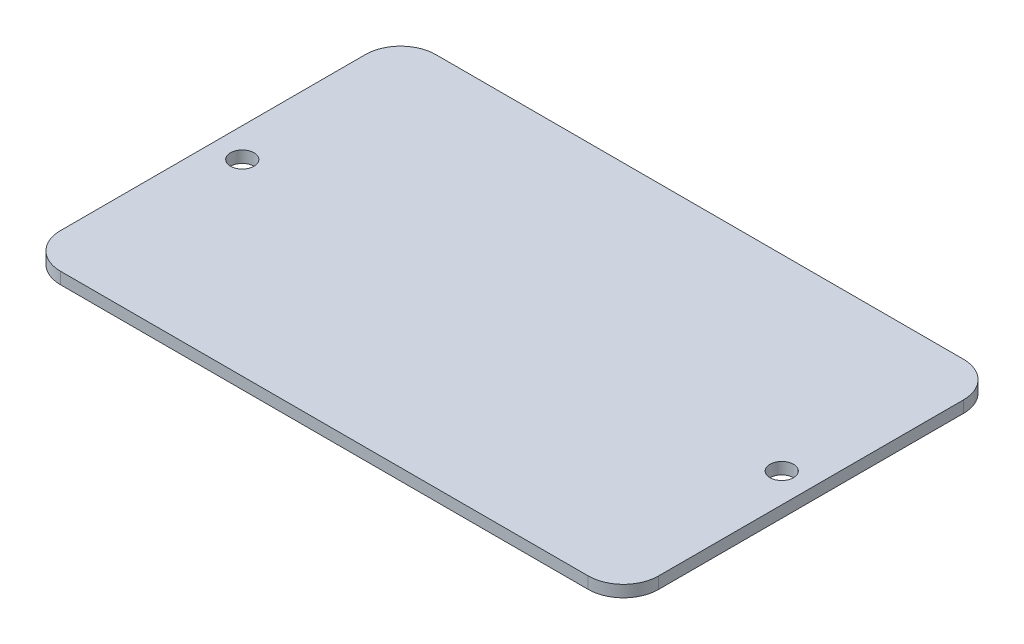
from build123d import *

# Parameters (mm, degrees)
SKETCH1_W           = 80.9625
SKETCH1_H           = 50.8
SKETCH1_R           = 1.5875
BOSS_EXTRUDE1_DEPTH = 1.5875
FILLET1_R           = 4.7625


with BuildPart() as part:
    # Sketch1 → Boss-Extrude1 (new body)
    with BuildSketch(Plane(origin=(0, 0, 0), x_dir=(1, 0, 0), z_dir=(0, 1, 0))):
        with Locations((40.48125, 25.4)):
            Rectangle(SKETCH1_W, SKETCH1_H)
        with Locations((3.96875, 25.4)):
            Circle(SKETCH1_R, mode=Mode.SUBTRACT)
        with Locations((76.99375, 25.4)):
            Circle(SKETCH1_R, mode=Mode.SUBTRACT)
    extrude(amount=BOSS_EXTRUDE1_DEPTH)

    # Fillet1
    fillet1_edges = [part.edges().sort_by_distance(p)[0] for p in [
        (0, 0.79375, -50.8),
        (80.9625, 0.79375, -50.8),
        (80.9625, 0.79375, 0),
        (0, 0.79375, 0),
    ]]
    fillet(fillet1_edges, radius=FILLET1_R)


solid = part.part
